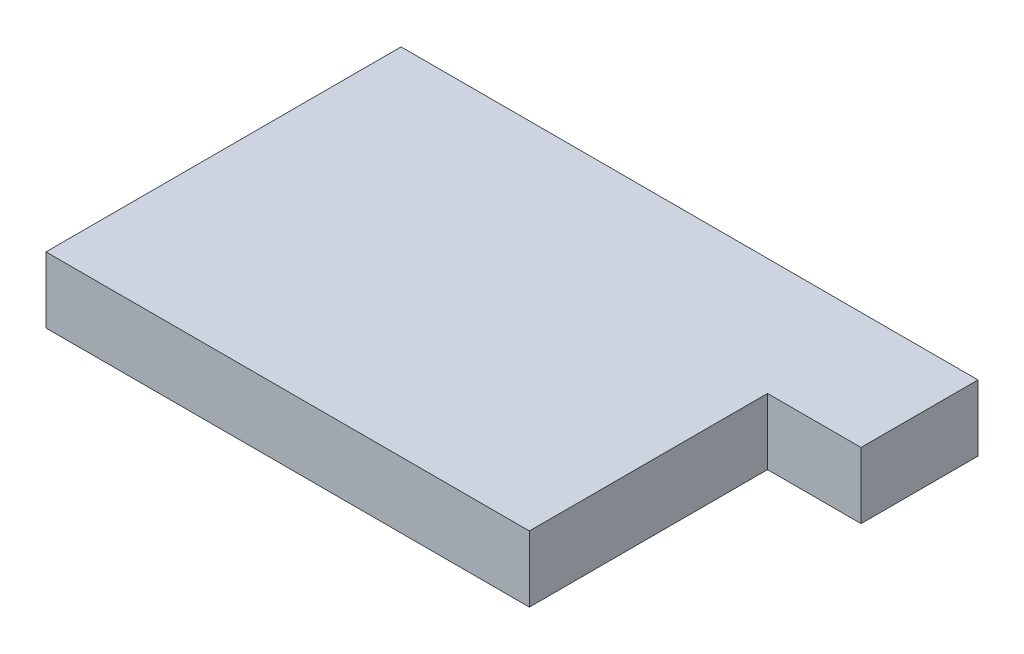
from build123d import *

# Parameters (mm, degrees)
BOSS_EXTRUDE1_DEPTH = 38.1


with BuildPart() as part:
    # Sketch1 → Boss-Extrude1 (new body)
    with BuildSketch(Plane(origin=(0, 0, 0), x_dir=(1, 0, 0), z_dir=(0, 1, 0))):
        Polygon((-139.55, 102.515), (139.55, 102.515), (193.55, 102.515), (193.55, 34.985), (139.55, 34.985), (139.55, -102.515), (-139.55, -102.515), align=None)
    extrude(amount=BOSS_EXTRUDE1_DEPTH)


solid = part.part
